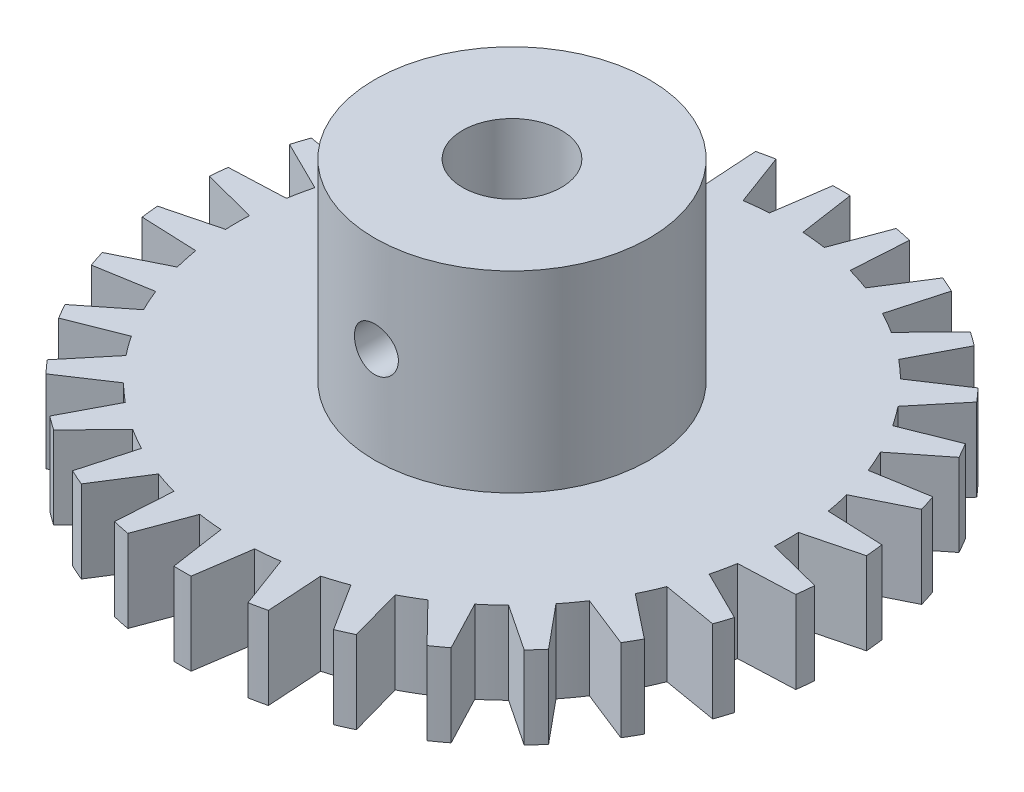
from build123d import *

# Parameters (mm, degrees)
BOSS_EXTRUDE1_DEPTH     = 3
SKETCH3_R               = 5
BOSS_EXTRUDE2_DEPTH     = 7
SKETCH2_R               = 1.8
CUT_EXTRUDE1_DEPTH      = 8
CUT_EXTRUDE1_DEPTH_BACK = 4
SKETCH4_R               = 0.8
CUT_EXTRUDE2_DEPTH      = 13


with BuildPart() as part:
    # Sketch1 → Boss-Extrude1 (new body)
    with BuildSketch(Plane(origin=(0, 0, 0), x_dir=(1, 0, 0), z_dir=(0, 1, 0))):
        with BuildLine():
            Line((-0.31412338, 11.9958879), (-0.610485395, 9.981347984))
            ThreePointArc((-0.610485395, 9.981347984), (-0.828082075, 9.965655025), (-1.045284633, 9.945218954))
            ThreePointArc((-1.045284633, 9.945218954), (-1.261989691, 9.920049497), (-1.478094111, 9.890158634))
            Line((-1.478094111, 9.890158634), (-2.186826306, 11.799058891))
            ThreePointArc((-2.186826306, 11.799058891), (-2.49494029, 11.737771209), (-2.801344366, 11.668439045))
            Line((-2.801344366, 11.668439045), (-2.672383761, 9.636304532))
            ThreePointArc((-2.672383761, 9.636304532), (-2.881962681, 9.575713608), (-3.090169944, 9.510565163))
            ThreePointArc((-3.090169944, 9.510565163), (-3.296906453, 9.440890204), (-3.502073813, 9.366721892))
            Line((-3.502073813, 9.366721892), (-4.592201188, 11.08655439))
            ThreePointArc((-4.592201188, 11.08655439), (-4.880839717, 10.962545492), (-5.166133162, 10.831023412))
            Line((-5.166133162, 10.831023412), (-4.617486132, 8.870108332))
            ThreePointArc((-4.617486132, 8.870108332), (-4.809887689, 8.767267557), (-5, 8.660254038))
            ThreePointArc((-5, 8.660254038), (-5.187732582, 8.549118707), (-5.372996083, 8.433914458))
            Line((-5.372996083, 8.433914458), (-6.796874843, 9.889514263))
            ThreePointArc((-6.796874843, 9.889514263), (-7.053423028, 9.708203932), (-7.305137148, 9.520240083))
            Line((-7.305137148, 9.520240083), (-6.360782203, 7.716245834))
            ThreePointArc((-6.360782203, 7.716245834), (-6.527597525, 7.575649844), (-6.691306064, 7.431448255))
            ThreePointArc((-6.691306064, 7.431448255), (-6.851829903, 7.283709699), (-7.009092643, 7.132504492))
            Line((-7.009092643, 7.132504492), (-8.704492452, 8.260254908))
            ThreePointArc((-8.704492452, 8.260254908), (-8.917737906, 8.029567276), (-9.124871587, 7.79337658))
            Line((-9.124871587, 7.79337658), (-7.826081569, 6.225146366))
            ThreePointArc((-7.826081569, 6.225146366), (-7.960020025, 6.05293988), (-8.090169944, 5.877852523))
            ThreePointArc((-8.090169944, 5.877852523), (-8.216469379, 5.699967626), (-8.338858221, 5.519369853))
            Line((-8.338858221, 5.519369853), (-10.231681972, 6.269982777))
            ThreePointArc((-10.231681972, 6.269982777), (-10.392304845, 6), (-10.545805352, 5.725905123))
            Line((-10.545805352, 5.725905123), (-8.949343616, 4.461978131))
            ThreePointArc((-8.949343616, 4.461978131), (-9.044551455, 4.265687399), (-9.135454576, 4.067366431))
            ThreePointArc((-9.135454576, 4.067366431), (-9.222009717, 3.867109616), (-9.30417568, 3.665012267))
            Line((-9.30417568, 3.665012267), (-11.311697893, 4.005682311))
            ThreePointArc((-11.311697893, 4.005682311), (-11.412678196, 3.708203932), (-11.505836818, 3.408184136))
            Line((-11.505836818, 3.408184136), (-9.681476404, 2.503800041))
            ThreePointArc((-9.681476404, 2.503800041), (-9.733792585, 2.292003909), (-9.781476007, 2.079116908))
            ThreePointArc((-9.781476007, 2.079116908), (-9.824503977, 1.86524036), (-9.862856015, 1.650476059))
            Line((-9.862856015, 1.650476059), (-11.897338336, 1.566314307))
            ThreePointArc((-11.897338336, 1.566314307), (-11.934262744, 1.254341559), (-11.963008005, 0.941509149))
            Line((-11.963008005, 0.941509149), (-9.990482216, 0.436193874))
            ThreePointArc((-9.990482216, 0.436193874), (-9.997620271, 0.21814885), (-10, 0))
            ThreePointArc((-10, 0), (-9.997620271, -0.21814885), (-9.990482216, -0.436193874))
            Line((-9.990482216, -0.436193874), (-11.963008005, -0.941509149))
            ThreePointArc((-11.963008005, -0.941509149), (-11.934262744, -1.254341559), (-11.897338336, -1.566314307))
            Line((-11.897338336, -1.566314307), (-9.862856015, -1.650476059))
            ThreePointArc((-9.862856015, -1.650476059), (-9.824503977, -1.86524036), (-9.781476007, -2.079116908))
            ThreePointArc((-9.781476007, -2.079116908), (-9.733792585, -2.292003909), (-9.681476404, -2.503800041))
            Line((-9.681476404, -2.503800041), (-11.505836818, -3.408184136))
            ThreePointArc((-11.505836818, -3.408184136), (-11.412678196, -3.708203932), (-11.311697893, -4.005682311))
            Line((-11.311697893, -4.005682311), (-9.30417568, -3.665012267))
            ThreePointArc((-9.30417568, -3.665012267), (-9.222009717, -3.867109616), (-9.135454576, -4.067366431))
            ThreePointArc((-9.135454576, -4.067366431), (-9.044551455, -4.265687399), (-8.949343616, -4.461978131))
            Line((-8.949343616, -4.461978131), (-10.545805352, -5.725905123))
            ThreePointArc((-10.545805352, -5.725905123), (-10.392304845, -6), (-10.231681972, -6.269982777))
            Line((-10.231681972, -6.269982777), (-8.338858221, -5.519369853))
            ThreePointArc((-8.338858221, -5.519369853), (-8.216469379, -5.699967626), (-8.090169944, -5.877852523))
            ThreePointArc((-8.090169944, -5.877852523), (-7.960020025, -6.05293988), (-7.826081569, -6.225146366))
            Line((-7.826081569, -6.225146366), (-9.124871587, -7.79337658))
            ThreePointArc((-9.124871587, -7.79337658), (-8.917737906, -8.029567276), (-8.704492452, -8.260254908))
            Line((-8.704492452, -8.260254908), (-7.009092643, -7.132504492))
            ThreePointArc((-7.009092643, -7.132504492), (-6.851829903, -7.283709699), (-6.691306064, -7.431448255))
            ThreePointArc((-6.691306064, -7.431448255), (-6.527597525, -7.575649844), (-6.360782203, -7.716245834))
            Line((-6.360782203, -7.716245834), (-7.305137148, -9.520240083))
            ThreePointArc((-7.305137148, -9.520240083), (-7.053423028, -9.708203932), (-6.796874843, -9.889514263))
            Line((-6.796874843, -9.889514263), (-5.372996083, -8.433914458))
            ThreePointArc((-5.372996083, -8.433914458), (-5.187732582, -8.549118707), (-5, -8.660254038))
            ThreePointArc((-5, -8.660254038), (-4.809887689, -8.767267557), (-4.617486132, -8.870108332))
            Line((-4.617486132, -8.870108332), (-5.166133162, -10.831023412))
            ThreePointArc((-5.166133162, -10.831023412), (-4.880839717, -10.962545492), (-4.592201188, -11.08655439))
            Line((-4.592201188, -11.08655439), (-3.502073813, -9.366721892))
            ThreePointArc((-3.502073813, -9.366721892), (-3.296906453, -9.440890204), (-3.090169944, -9.510565163))
            ThreePointArc((-3.090169944, -9.510565163), (-2.881962681, -9.575713608), (-2.672383761, -9.636304532))
            Line((-2.672383761, -9.636304532), (-2.801344366, -11.668439045))
            ThreePointArc((-2.801344366, -11.668439045), (-2.49494029, -11.737771209), (-2.186826306, -11.799058891))
            Line((-2.186826306, -11.799058891), (-1.478094111, -9.890158634))
            ThreePointArc((-1.478094111, -9.890158634), (-1.261989691, -9.920049497), (-1.045284633, -9.945218954))
            ThreePointArc((-1.045284633, -9.945218954), (-0.828082075, -9.965655025), (-0.610485395, -9.981347984))
            Line((-0.610485395, -9.981347984), (-0.31412338, -11.9958879))
            ThreePointArc((-0.31412338, -11.9958879), (0, -12), (0.31412338, -11.9958879))
            Line((0.31412338, -11.9958879), (0.610485395, -9.981347984))
            ThreePointArc((0.610485395, -9.981347984), (0.828082075, -9.965655025), (1.045284633, -9.945218954))
            ThreePointArc((1.045284633, -9.945218954), (1.261989691, -9.920049497), (1.478094111, -9.890158634))
            Line((1.478094111, -9.890158634), (2.186826306, -11.799058891))
            ThreePointArc((2.186826306, -11.799058891), (2.49494029, -11.737771209), (2.801344366, -11.668439045))
            Line((2.801344366, -11.668439045), (2.672383761, -9.636304532))
            ThreePointArc((2.672383761, -9.636304532), (2.881962681, -9.575713608), (3.090169944, -9.510565163))
            ThreePointArc((3.090169944, -9.510565163), (3.296906453, -9.440890204), (3.502073813, -9.366721892))
            Line((3.502073813, -9.366721892), (4.592201188, -11.08655439))
            ThreePointArc((4.592201188, -11.08655439), (4.880839717, -10.962545492), (5.166133162, -10.831023412))
            Line((5.166133162, -10.831023412), (4.617486132, -8.870108332))
            ThreePointArc((4.617486132, -8.870108332), (4.809887689, -8.767267557), (5, -8.660254038))
            ThreePointArc((5, -8.660254038), (5.187732582, -8.549118707), (5.372996083, -8.433914458))
            Line((5.372996083, -8.433914458), (6.796874843, -9.889514263))
            ThreePointArc((6.796874843, -9.889514263), (7.053423028, -9.708203932), (7.305137148, -9.520240083))
            Line((7.305137148, -9.520240083), (6.360782203, -7.716245834))
            ThreePointArc((6.360782203, -7.716245834), (6.527597525, -7.575649844), (6.691306064, -7.431448255))
            ThreePointArc((6.691306064, -7.431448255), (6.851829903, -7.283709699), (7.009092643, -7.132504492))
            Line((7.009092643, -7.132504492), (8.704492452, -8.260254908))
            ThreePointArc((8.704492452, -8.260254908), (8.917737906, -8.029567276), (9.124871587, -7.79337658))
            Line((9.124871587, -7.79337658), (7.826081569, -6.225146366))
            ThreePointArc((7.826081569, -6.225146366), (7.960020025, -6.05293988), (8.090169944, -5.877852523))
            ThreePointArc((8.090169944, -5.877852523), (8.216469379, -5.699967626), (8.338858221, -5.519369853))
            Line((8.338858221, -5.519369853), (10.231681972, -6.269982777))
            ThreePointArc((10.231681972, -6.269982777), (10.392304845, -6), (10.545805352, -5.725905123))
            Line((10.545805352, -5.725905123), (8.949343616, -4.461978131))
            ThreePointArc((8.949343616, -4.461978131), (9.044551455, -4.265687399), (9.135454576, -4.067366431))
            ThreePointArc((9.135454576, -4.067366431), (9.222009717, -3.867109616), (9.30417568, -3.665012267))
            Line((9.30417568, -3.665012267), (11.311697893, -4.005682311))
            ThreePointArc((11.311697893, -4.005682311), (11.412678196, -3.708203932), (11.505836818, -3.408184136))
            Line((11.505836818, -3.408184136), (9.681476404, -2.503800041))
            ThreePointArc((9.681476404, -2.503800041), (9.733792585, -2.292003909), (9.781476007, -2.079116908))
            ThreePointArc((9.781476007, -2.079116908), (9.824503977, -1.86524036), (9.862856015, -1.650476059))
            Line((9.862856015, -1.650476059), (11.897338336, -1.566314307))
            ThreePointArc((11.897338336, -1.566314307), (11.934262744, -1.254341559), (11.963008005, -0.941509149))
            Line((11.963008005, -0.941509149), (9.990482216, -0.436193874))
            ThreePointArc((9.990482216, -0.436193874), (9.997620271, -0.21814885), (10, 0))
            ThreePointArc((10, 0), (9.997620271, 0.21814885), (9.990482216, 0.436193874))
            Line((9.990482216, 0.436193874), (11.963008005, 0.941509149))
            ThreePointArc((11.963008005, 0.941509149), (11.934262744, 1.254341559), (11.897338336, 1.566314307))
            Line((11.897338336, 1.566314307), (9.862856015, 1.650476059))
            ThreePointArc((9.862856015, 1.650476059), (9.824503977, 1.86524036), (9.781476007, 2.079116908))
            ThreePointArc((9.781476007, 2.079116908), (9.733792585, 2.292003909), (9.681476404, 2.503800041))
            Line((9.681476404, 2.503800041), (11.505836818, 3.408184136))
            ThreePointArc((11.505836818, 3.408184136), (11.412678196, 3.708203932), (11.311697893, 4.005682311))
            Line((11.311697893, 4.005682311), (9.30417568, 3.665012267))
            ThreePointArc((9.30417568, 3.665012267), (9.222009717, 3.867109616), (9.135454576, 4.067366431))
            ThreePointArc((9.135454576, 4.067366431), (9.044551455, 4.265687399), (8.949343616, 4.461978131))
            Line((8.949343616, 4.461978131), (10.545805352, 5.725905123))
            ThreePointArc((10.545805352, 5.725905123), (10.392304845, 6), (10.231681972, 6.269982777))
            Line((10.231681972, 6.269982777), (8.338858221, 5.519369853))
            ThreePointArc((8.338858221, 5.519369853), (8.216469379, 5.699967626), (8.090169944, 5.877852523))
            ThreePointArc((8.090169944, 5.877852523), (7.960020025, 6.05293988), (7.826081569, 6.225146366))
            Line((7.826081569, 6.225146366), (9.124871587, 7.79337658))
            ThreePointArc((9.124871587, 7.79337658), (8.917737906, 8.029567276), (8.704492452, 8.260254908))
            Line((8.704492452, 8.260254908), (7.009092643, 7.132504492))
            ThreePointArc((7.009092643, 7.132504492), (6.851829903, 7.283709699), (6.691306064, 7.431448255))
            ThreePointArc((6.691306064, 7.431448255), (6.527597525, 7.575649844), (6.360782203, 7.716245834))
            Line((6.360782203, 7.716245834), (7.305137148, 9.520240083))
            ThreePointArc((7.305137148, 9.520240083), (7.053423028, 9.708203932), (6.796874843, 9.889514263))
            Line((6.796874843, 9.889514263), (5.372996083, 8.433914458))
            ThreePointArc((5.372996083, 8.433914458), (5.187732582, 8.549118707), (5, 8.660254038))
            ThreePointArc((5, 8.660254038), (4.809887689, 8.767267557), (4.617486132, 8.870108332))
            Line((4.617486132, 8.870108332), (5.166133162, 10.831023412))
            ThreePointArc((5.166133162, 10.831023412), (4.880839717, 10.962545492), (4.592201188, 11.08655439))
            Line((4.592201188, 11.08655439), (3.502073813, 9.366721892))
            ThreePointArc((3.502073813, 9.366721892), (3.296906453, 9.440890204), (3.090169944, 9.510565163))
            ThreePointArc((3.090169944, 9.510565163), (2.881962681, 9.575713608), (2.672383761, 9.636304532))
            Line((2.672383761, 9.636304532), (2.801344366, 11.668439045))
            ThreePointArc((2.801344366, 11.668439045), (2.49494029, 11.737771209), (2.186826306, 11.799058891))
            Line((2.186826306, 11.799058891), (1.478094111, 9.890158634))
            ThreePointArc((1.478094111, 9.890158634), (1.261989691, 9.920049497), (1.045284633, 9.945218954))
            ThreePointArc((1.045284633, 9.945218954), (0.828082075, 9.965655025), (0.610485395, 9.981347984))
            Line((0.610485395, 9.981347984), (0.31412338, 11.9958879))
            ThreePointArc((0.31412338, 11.9958879), (0, 12), (-0.31412338, 11.9958879))
        make_face()
    extrude(amount=BOSS_EXTRUDE1_DEPTH)

    # Sketch3 → Boss-Extrude2 (add)
    with BuildSketch(Plane(origin=(0, 3, 0), x_dir=(1, 0, 0), z_dir=(0, 1, 0))):
        Circle(SKETCH3_R)
    extrude(amount=BOSS_EXTRUDE2_DEPTH)

    # Sketch2 → Cut-Extrude1 (cut, two sides)
    with BuildSketch(Plane(origin=(0, 3, 0), x_dir=(1, 0, 0), z_dir=(0, 1, 0))) as cut_extrude1_sk:
        Circle(SKETCH2_R)
    extrude(amount=CUT_EXTRUDE1_DEPTH, mode=Mode.SUBTRACT)
    extrude(cut_extrude1_sk.sketch, amount=-CUT_EXTRUDE1_DEPTH_BACK, mode=Mode.SUBTRACT)

    # Sketch4 → Cut-Extrude2 (cut, through all)
    with BuildSketch(Plane.XY):
        with Locations((0, 6.5)):
            Circle(SKETCH4_R)
    extrude(amount=CUT_EXTRUDE2_DEPTH, mode=Mode.SUBTRACT)


solid = part.part
